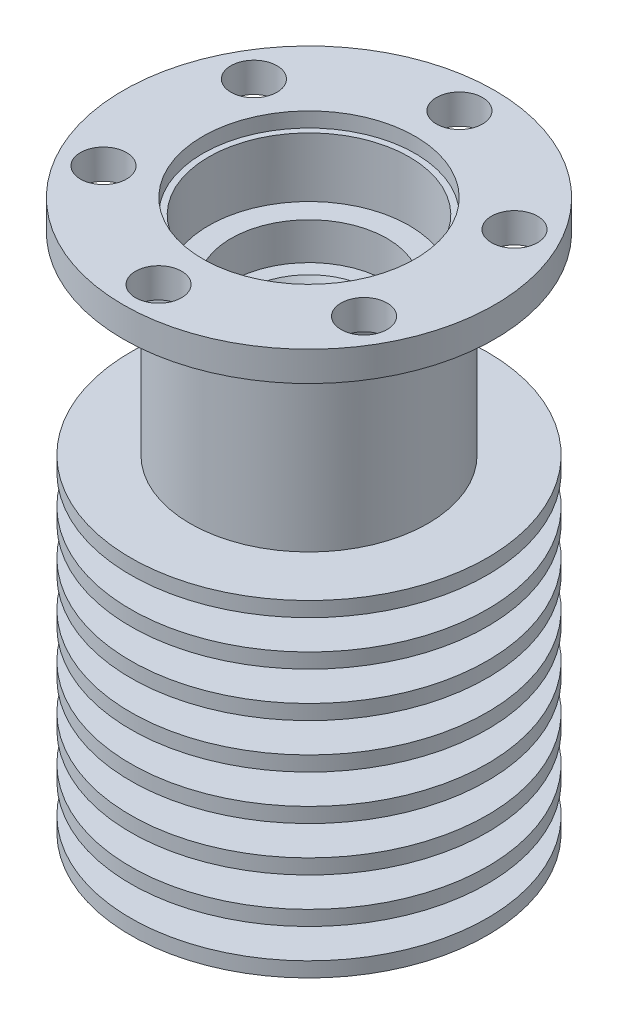
from build123d import *

# Parameters (mm, degrees)
CROQUIS3_R              = 12
CROQUIS3_R_2            = 3.25
SALIENTE_EXTRUIR1_DEPTH = 1
MATRIZL1_COUNT          = 8
MATRIZL1_PITCH          = 3
CROQUIS5_R              = 1.55
CORTAR_EXTRUIR1_DEPTH   = 2
MATRIZC1_COUNT          = 6
CHAFL_N3_SIZE           = 0.3
CHAFL_N3_SIZE2          = 0.519615242
CROQUIS6_R              = 7.15
CORTAR_EXTRUIR2_DEPTH   = 1
CHAFL_N2_SIZE           = 0.15
CHAFL_N2_SIZE2          = 0.259807621
CHAFL_N4_SIZE           = 1
CHAFL_N4_SIZE2          = 1.732050808


with BuildPart() as part:
    # Croquis1 → Revolución1 (revolve)
    with BuildSketch(Plane.XY):
        Polygon((0, 0), (6, 0), (6, 9), (5.25, 9), (5.25, 12), (4.75, 12), (4.75, 22), (8, 22), (8, 35), (12.5, 35), (12.5, 37), (0, 37), align=None)
    revolve(axis=Axis((0, 37, 0), (0, -1, 0)))

    # Croquis2 → Cortar-Revolución1 (revolve, cut)
    with BuildSketch(Plane.XY):
        Polygon((0, 0), (2.5, 0), (2.5, 12), (1.7, 12), (1.7, 14), (3.25, 14), (3.25, 29.5), (5.25, 29.5), (5.25, 32), (6.75, 32), (6.75, 37), (0, 37), align=None)
    revolve(axis=Axis((0, 0, 0), (0, 1, 0)), mode=Mode.SUBTRACT)

    # Croquis3 → Saliente-Extruir1 (add)
    with BuildSketch(Plane.XZ):
        Circle(CROQUIS3_R)
        Circle(CROQUIS3_R_2, mode=Mode.SUBTRACT)
    saliente_extruir1 = extrude(amount=-SALIENTE_EXTRUIR1_DEPTH)

    # MatrizL1: Saliente-Extruir1 ×8
    with Locations(*[(0, i * MATRIZL1_PITCH, 0) for i in range(1, MATRIZL1_COUNT)]):
        add(saliente_extruir1)

    # Croquis5 → Cortar-Extruir1 (cut)
    with BuildSketch(Plane(origin=(0, 37, 0), x_dir=(1, 0, 0), z_dir=(0, 1, 0))):
        with Locations((0, 10.125)):
            Circle(CROQUIS5_R)
    cortar_extruir1 = extrude(amount=-CORTAR_EXTRUIR1_DEPTH, mode=Mode.SUBTRACT)

    # MatrizC1: Cortar-Extruir1 ×6 about axis
    matrizc1_axis = Axis((0, 0, 0), (0, 1, 0))
    for i in range(1, MATRIZC1_COUNT):
        add(cortar_extruir1.rotate(matrizc1_axis, i * 360 / MATRIZC1_COUNT), mode=Mode.SUBTRACT)

    # Chaflán3
    chafl_n3_edges = [part.edges().sort_by_distance(p)[0] for p in [
        (-1.7, 14, 0),
    ]]
    chafl_n3_side = [part.faces().sort_by_distance(p)[0] for p in [
        (-1.791923882, 14, 0),
    ]]
    chamfer(chafl_n3_edges, length=CHAFL_N3_SIZE, length2=CHAFL_N3_SIZE2, reference=chafl_n3_side[0])

    # Croquis6 → Cortar-Extruir2 (cut)
    with BuildSketch(Plane(origin=(0, 37, 0), x_dir=(1, 0, 0), z_dir=(0, 1, 0))):
        Circle(CROQUIS6_R)
    extrude(amount=-CORTAR_EXTRUIR2_DEPTH, mode=Mode.SUBTRACT)

    # Chaflán2
    chafl_n2_edges = [part.edges().sort_by_distance(p)[0] for p in [
        (-1.7, 12, 0),
    ]]
    chafl_n2_side = [part.faces().sort_by_distance(p)[0] for p in [
        (-2.429289322, 12, 0),
    ]]
    chamfer(chafl_n2_edges, length=CHAFL_N2_SIZE, length2=CHAFL_N2_SIZE2, reference=chafl_n2_side[0])

    # Chaflán4
    chafl_n4_edges = [part.edges().sort_by_distance(p)[0] for p in [
        (-3.25, 29.5, 0),
    ]]
    chafl_n4_side = [part.faces().sort_by_distance(p)[0] for p in [
        (-3.398492424, 29.5, 0),
    ]]
    chamfer(chafl_n4_edges, length=CHAFL_N4_SIZE, length2=CHAFL_N4_SIZE2, reference=chafl_n4_side[0])


solid = part.part
